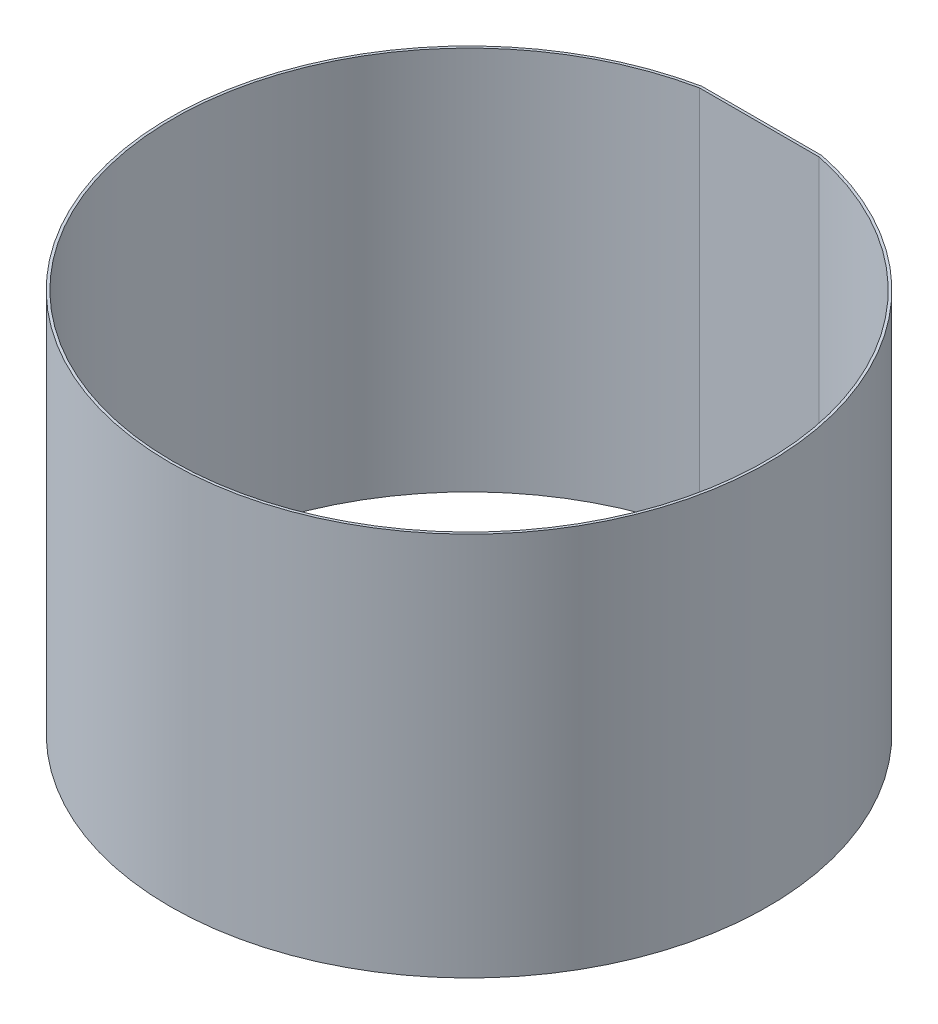
from build123d import *

# Parameters (mm, degrees)
BOSS_EXTRUDE1_DEPTH = 225


with BuildPart() as part:
    # Sketch1 → Boss-Extrude1 (new body)
    with BuildSketch(Plane(origin=(0, 0, 0), x_dir=(1, 0, 0), z_dir=(0, 1, 0))):
        with BuildLine():
            Line((-35.152535823, 171.433075062), (35.152535823, 171.433075062))
            ThreePointArc((35.152535823, 171.433075062), (0, -175), (-35.152535823, 171.433075062))
        make_face()
        with BuildLine():
            ThreePointArc((-35, 169.933075062), (0, -173.5), (35, 169.933075062))
            Line((35, 169.933075062), (-35, 169.933075062))
        make_face(mode=Mode.SUBTRACT)
    extrude(amount=BOSS_EXTRUDE1_DEPTH)


solid = part.part
